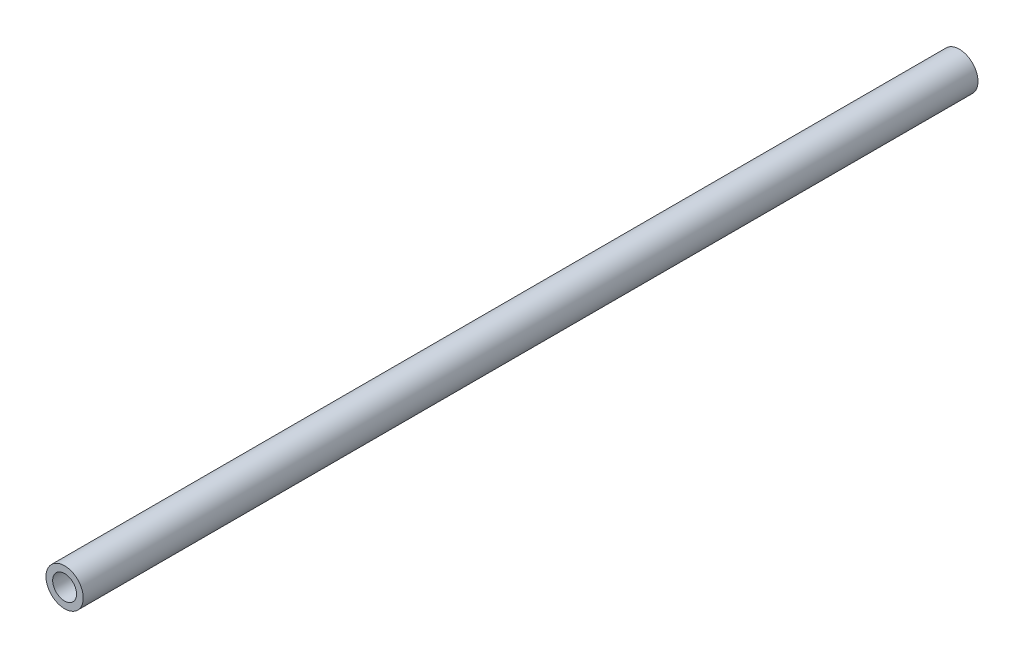
from build123d import *

# Parameters (mm, degrees)
SKETCH_1_R      = 2.5
SKETCH_1_R_2    = 1.6
EXTRUDE_1_DEPTH = 60


with BuildPart() as part:
    # 草图1 → 凸台-拉伸1 (new body, symmetric)
    with BuildSketch(Plane.XY):
        Circle(SKETCH_1_R)
        Circle(SKETCH_1_R_2, mode=Mode.SUBTRACT)
    extrude(amount=EXTRUDE_1_DEPTH, both=True)


solid = part.part
